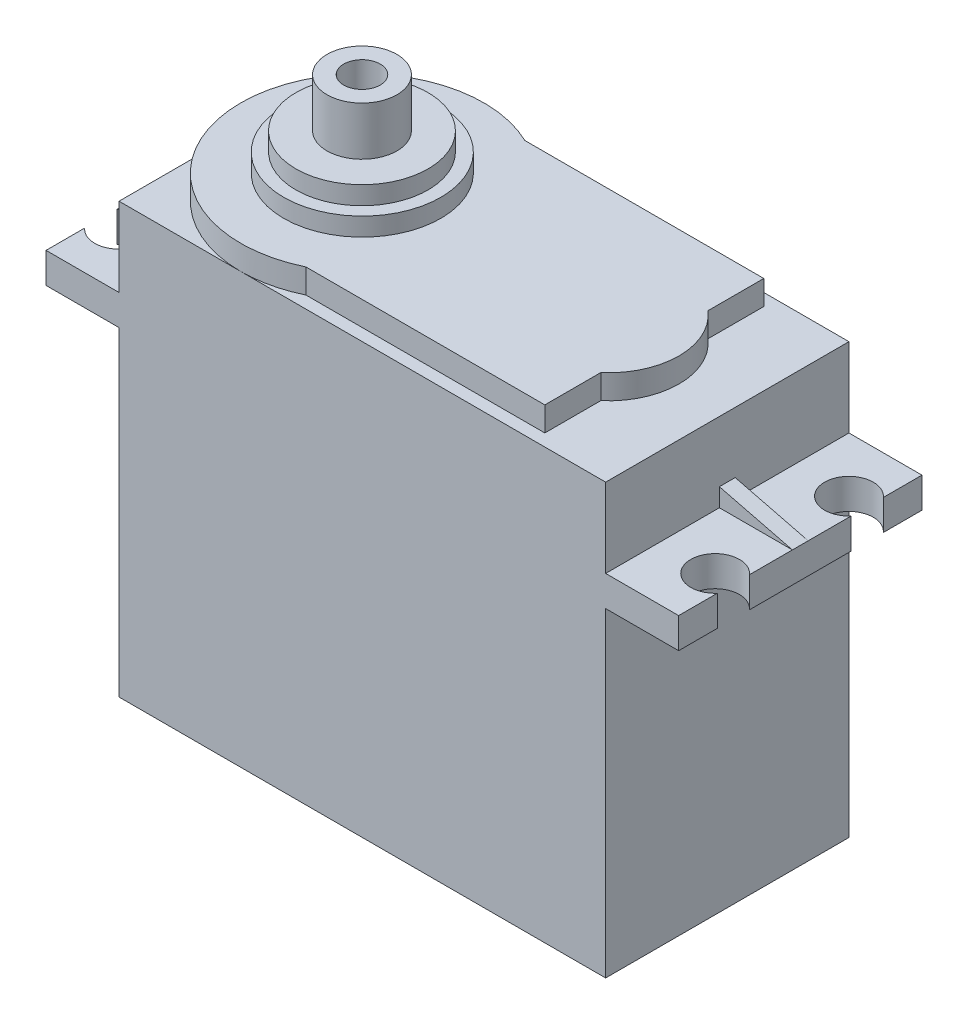
from build123d import *

# Parameters (mm, degrees)
SKETCH1_W            = 40
SKETCH1_H            = 20
BOSS_EXTRUDE1_DEPTH  = 35.3
BOSS_EXTRUDE2_DEPTH  = 2
SKETCH3_R            = 6.458580866
BOSS_EXTRUDE3_DEPTH  = 1.5
SKETCH4_R            = 5.433415679
BOSS_EXTRUDE4_DEPTH  = 1.5
SKETCH5_R            = 2.875
BOSS_EXTRUDE5_DEPTH  = 4
SKETCH6_W            = 20
SKETCH6_H            = 2.5
BOSS_EXTRUDE6_DEPTH  = 6
CUT_EXTRUDE1_DEPTH   = 7
SKETCH8_W            = 20
SKETCH8_H            = 2.5
BOSS_EXTRUDE7_DEPTH  = 6
CUT_EXTRUDE2_DEPTH   = 7
SKETCH11_W           = 7
SKETCH11_H           = 4
BOSS_EXTRUDE8_DEPTH  = 6
SKETCH12_W           = 6.5
SKETCH12_H           = 3.5
CUT_EXTRUDE3_DEPTH   = 6
SKETCH13_W           = 6
SKETCH13_H           = 1.3
BOSS_EXTRUDE9_DEPTH  = 1.5
SKETCH14_W           = 6
SKETCH14_H           = 1.3
BOSS_EXTRUDE10_DEPTH = 1.5
CUT_EXTRUDE4_DEPTH   = 1.5
CUT_EXTRUDE5_DEPTH   = 1.5
SKETCH17_R           = 1.5
CUT_EXTRUDE6_DEPTH   = 4


with BuildPart() as part:
    # Sketch1 → Boss-Extrude1 (new body)
    with BuildSketch(Plane(origin=(0, 0, 0), x_dir=(1, 0, 0), z_dir=(0, 1, 0))):
        with Locations((20, 10)):
            Rectangle(SKETCH1_W, SKETCH1_H)
    extrude(amount=BOSS_EXTRUDE1_DEPTH)

    # Sketch2 → Boss-Extrude2 (add)
    with BuildSketch(Plane(origin=(0, 35.3, 0), x_dir=(1, 0, 0), z_dir=(0, 1, 0))):
        with BuildLine():
            Line((34, 5.599382986), (34, 1))
            Line((34, 1), (14.359898944, 1))
            ThreePointArc((14.359898944, 1), (0.001, 10), (14.359898944, 19))
            Line((14.359898944, 19), (34, 19))
            Line((34, 19), (34, 14.400617014))
            ThreePointArc((34, 14.400617014), (36.031185557, 10), (34, 5.599382986))
        make_face()
    extrude(amount=BOSS_EXTRUDE2_DEPTH)

    # Sketch3 → Boss-Extrude3 (add)
    with BuildSketch(Plane(origin=(0, 37.3, 0), x_dir=(1, 0, 0), z_dir=(0, 1, 0))):
        with Locations((9.993186342, 10)):
            Circle(SKETCH3_R)
    extrude(amount=BOSS_EXTRUDE3_DEPTH)

    # Sketch4 → Boss-Extrude4 (add)
    with BuildSketch(Plane(origin=(0, 38.8, 0), x_dir=(1, 0, 0), z_dir=(0, 1, 0))):
        with Locations((9.970242147, 10)):
            Circle(SKETCH4_R)
    extrude(amount=BOSS_EXTRUDE4_DEPTH)

    # Sketch5 → Boss-Extrude5 (add)
    with BuildSketch(Plane(origin=(0, 40.3, 0), x_dir=(1, 0, 0), z_dir=(0, 1, 0))):
        with Locations((9.970242147, 10)):
            Circle(SKETCH5_R)
    extrude(amount=BOSS_EXTRUDE5_DEPTH)

    # Sketch6 → Boss-Extrude6 (add)
    with BuildSketch(Plane(origin=(40, 0, 0), x_dir=(0, 0, -1), z_dir=(1, 0, 0))):
        with Locations((10, 27.55)):
            Rectangle(SKETCH6_W, SKETCH6_H)
    extrude(amount=BOSS_EXTRUDE6_DEPTH)

    # Sketch7 → Cut-Extrude1 (cut)
    with BuildSketch(Plane(origin=(0, 28.8, 0), x_dir=(1, 0, 0), z_dir=(0, 1, 0))):
        with BuildLine():
            ThreePointArc((46, 3.177124344), (46.370828693, 3.792893219), (46.5, 4.5))
            ThreePointArc((46.5, 4.5), (46.370828693, 5.207106781), (46, 5.822875656))
            Line((46, 5.822875656), (46, 3.177124344))
        make_face()
        with BuildLine():
            Line((46, 3.177124344), (46, 5.822875656))
            ThreePointArc((46, 5.822875656), (43.792893219, 6.370828693), (42.5, 4.5))
            ThreePointArc((42.5, 4.5), (43.792893219, 2.629171307), (46, 3.177124344))
        make_face()
        with BuildLine():
            ThreePointArc((42.5, 15.5), (43.792893219, 13.629171307), (46, 14.177124344))
            Line((46, 14.177124344), (46, 16.822875656))
            ThreePointArc((46, 16.822875656), (43.792893219, 17.370828693), (42.5, 15.5))
        make_face()
        with BuildLine():
            Line((46, 16.822875656), (46, 14.177124344))
            ThreePointArc((46, 14.177124344), (46.370828693, 14.792893219), (46.5, 15.5))
            ThreePointArc((46.5, 15.5), (46.370828693, 16.207106781), (46, 16.822875656))
        make_face()
    extrude(amount=-CUT_EXTRUDE1_DEPTH, mode=Mode.SUBTRACT)

    # Sketch8 → Boss-Extrude7 (add)
    with BuildSketch(Plane.ZY):
        with Locations((-10, 27.55)):
            Rectangle(SKETCH8_W, SKETCH8_H)
    extrude(amount=BOSS_EXTRUDE7_DEPTH)

    # Sketch9 → Cut-Extrude2 (cut)
    with BuildSketch(Plane(origin=(0, 28.8, 0), x_dir=(1, 0, 0), z_dir=(0, 1, 0))):
        with BuildLine():
            ThreePointArc((-6, 14.177124344), (-3.792893219, 13.629171307), (-2.5, 15.5))
            ThreePointArc((-2.5, 15.5), (-3.792893219, 17.370828693), (-6, 16.822875656))
            Line((-6, 16.822875656), (-6, 14.177124344))
        make_face()
        with BuildLine():
            Line((-6, 14.177124344), (-6, 16.822875656))
            ThreePointArc((-6, 16.822875656), (-6.5, 15.5), (-6, 14.177124344))
        make_face()
        with BuildLine():
            ThreePointArc((-2.5, 4.5), (-3.792893219, 6.370828693), (-6, 5.822875656))
            Line((-6, 5.822875656), (-6, 3.177124344))
            ThreePointArc((-6, 3.177124344), (-3.792893219, 2.629171307), (-2.5, 4.5))
        make_face()
        with BuildLine():
            Line((-6, 3.177124344), (-6, 5.822875656))
            ThreePointArc((-6, 5.822875656), (-6.5, 4.5), (-6, 3.177124344))
        make_face()
    extrude(amount=-CUT_EXTRUDE2_DEPTH, mode=Mode.SUBTRACT)

    # Sketch11 → Boss-Extrude8 (add)
    with BuildSketch(Plane.ZY):
        with Locations((-10.225128457, 8.7)):
            Rectangle(SKETCH11_W, SKETCH11_H)
    extrude(amount=BOSS_EXTRUDE8_DEPTH)

    # Sketch12 → Cut-Extrude3 (cut)
    with BuildSketch(Plane.ZY.offset(6)):
        with Locations((-10.225128457, 8.7)):
            Rectangle(SKETCH12_W, SKETCH12_H)
    extrude(amount=-CUT_EXTRUDE3_DEPTH, mode=Mode.SUBTRACT)

    # Sketch13 → Boss-Extrude9 (add)
    with BuildSketch(Plane(origin=(0, 28.8, 0), x_dir=(1, 0, 0), z_dir=(0, 1, 0))):
        with Locations((43, 10)):
            Rectangle(SKETCH13_W, SKETCH13_H)
    extrude(amount=BOSS_EXTRUDE9_DEPTH)

    # Sketch14 → Boss-Extrude10 (add)
    with BuildSketch(Plane(origin=(0, 28.8, 0), x_dir=(1, 0, 0), z_dir=(0, 1, 0))):
        with Locations((-3, 10)):
            Rectangle(SKETCH14_W, SKETCH14_H)
    extrude(amount=BOSS_EXTRUDE10_DEPTH)

    # Sketch15 → Cut-Extrude4 (cut)
    with BuildSketch(Plane.XY.offset(-9.35)):
        Polygon((40, 30.3), (46, 28.8), (46, 30.3), align=None)
    extrude(amount=-CUT_EXTRUDE4_DEPTH, mode=Mode.SUBTRACT)

    # Sketch16 → Cut-Extrude5 (cut)
    with BuildSketch(Plane.XY.offset(-9.35)):
        Polygon((-6, 28.8), (-6, 30.3), (0, 30.3), align=None)
    extrude(amount=-CUT_EXTRUDE5_DEPTH, mode=Mode.SUBTRACT)

    # Sketch17 → Cut-Extrude6 (cut)
    with BuildSketch(Plane(origin=(0, 44.3, 0), x_dir=(1, 0, 0), z_dir=(0, 1, 0))):
        with Locations((9.970242147, 10)):
            Circle(SKETCH17_R)
    extrude(amount=-CUT_EXTRUDE6_DEPTH, mode=Mode.SUBTRACT)


solid = part.part
